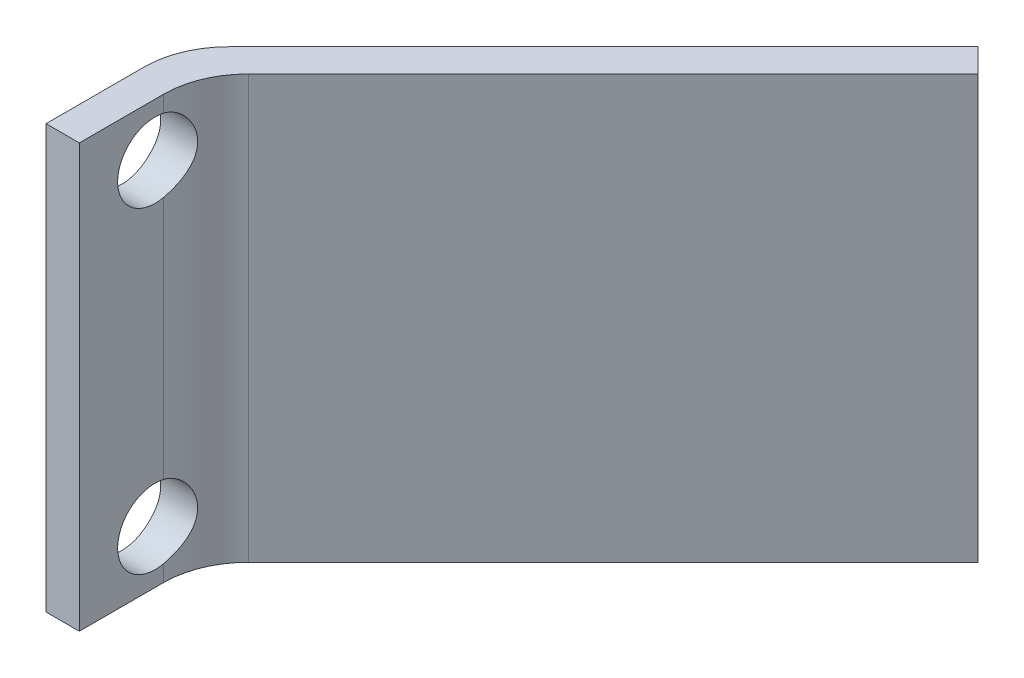
from build123d import *

# Parameters (mm, degrees)
SKETCH1_W               = 1
SKETCH1_H               = 4
BOSS_EXTRUDE1_DEPTH     = 12.7
BOSS_EXTRUDE2_DEPTH     = 12.7
FILLET1_R               = 2.54
SKETCH3_R               = 1.125
CUT_EXTRUDE1_DEPTH      = 24.536198366
CUT_EXTRUDE1_DEPTH_BACK = 24.536198366


with BuildPart() as part:
    # Sketch1 → Boss-Extrude1 (new body)
    with BuildSketch(Plane(origin=(0, 0, 0), x_dir=(1, 0, 0), z_dir=(0, 1, 0))):
        with Locations((0.5, 2)):
            Rectangle(SKETCH1_W, SKETCH1_H)
    extrude(amount=BOSS_EXTRUDE1_DEPTH)

    # Sketch2 → Boss-Extrude2 (add)
    with BuildSketch(Plane(origin=(0, 0, 0), x_dir=(1, 0, 0), z_dir=(0, 1, 0))):
        Polygon((0, 4), (11.992893219, 15.992893219), (12.7, 15.285786438), (0.707106781, 3.292893219), align=None)
    extrude(amount=BOSS_EXTRUDE2_DEPTH)

    # Fillet1
    fillet1_edges = [part.edges().sort_by_distance(p)[0] for p in [
        (1, 6.35, -3.585786438),
        (0, 6.35, -4),
    ]]
    fillet(fillet1_edges, radius=FILLET1_R)

    # Sketch3 → Cut-Extrude1 (cut, two sides)
    with BuildSketch(Plane(origin=(1, 0, 0), x_dir=(0, 0, -1), z_dir=(1, 0, 0))) as cut_extrude1_sk:
        with Locations(Location((2.276792488, 11.1125, 0), (0, 0, 306.622338606))):
            Circle(SKETCH3_R)
        with Locations(Location((2.276792488, 1.5875, 0), (0, 0, 306.622338606))):
            Circle(SKETCH3_R)
    extrude(amount=CUT_EXTRUDE1_DEPTH, mode=Mode.SUBTRACT)
    extrude(cut_extrude1_sk.sketch, amount=-CUT_EXTRUDE1_DEPTH_BACK, mode=Mode.SUBTRACT)


solid = part.part
